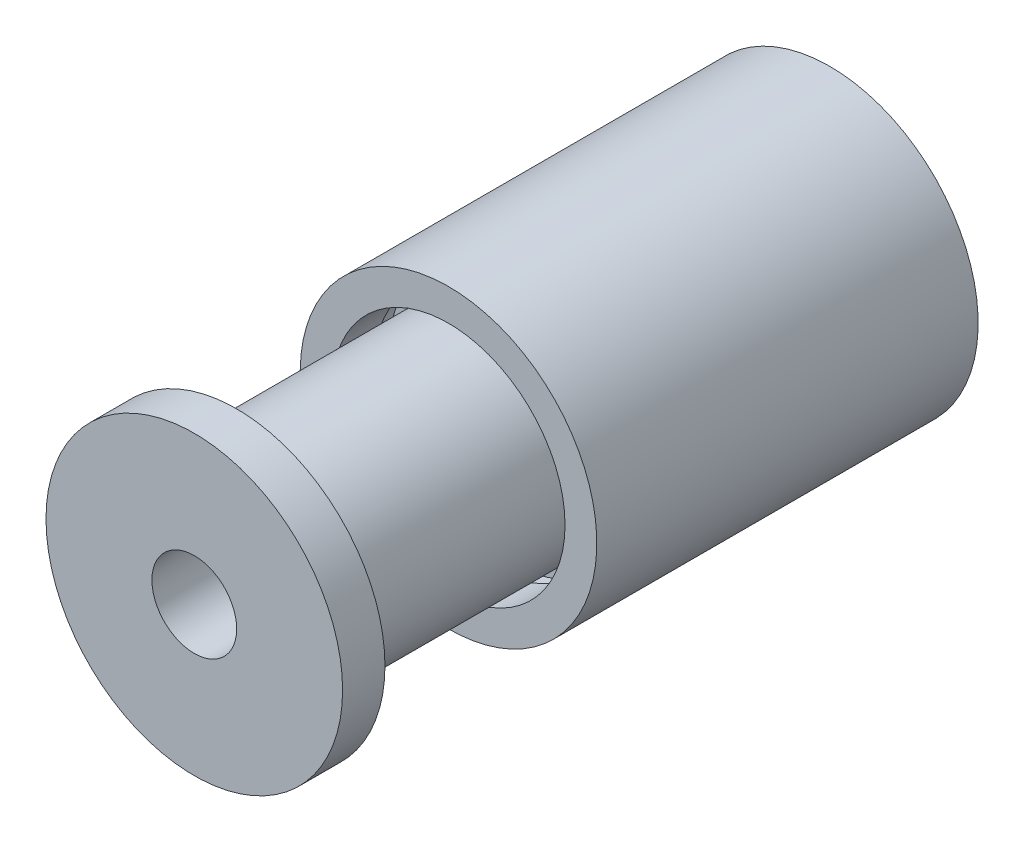
from build123d import *

# Parameters (mm, degrees)
CROQUIS1_R              = 25
CROQUIS1_R_2            = 10
SALIENTE_EXTRUIR1_DEPTH = 70
CROQUIS3_R              = 35
CROQUIS3_R_2            = 25
SALIENTE_EXTRUIR2_DEPTH = 10
CROQUIS4_R              = 30
CROQUIS4_R_2            = 27.5
SALIENTE_EXTRUIR3_DEPTH = 10
CROQUIS6_RX             = 35
CROQUIS6_RY             = 35
CROQUIS6_RX_2           = 30
CROQUIS6_RY_2           = 30
SALIENTE_EXTRUIR4_DEPTH = 90
CROQUIS7_R              = 25
CROQUIS7_R_2            = 10
SALIENTE_EXTRUIR5_DEPTH = 10
CROQUIS8_R              = 29
CROQUIS8_R_2            = 25
SALIENTE_EXTRUIR6_DEPTH = 5


with BuildPart() as part:
    # Croquis1 → Saliente-Extruir1 (new body)
    with BuildSketch(Plane.XY):
        Circle(CROQUIS1_R)
        Circle(CROQUIS1_R_2, mode=Mode.SUBTRACT)
    extrude(amount=SALIENTE_EXTRUIR1_DEPTH)

    # Croquis3 → Saliente-Extruir2 (add)
    with BuildSketch(Plane.XY.offset(70)):
        Circle(CROQUIS3_R)
        Circle(CROQUIS3_R_2, mode=Mode.SUBTRACT)
    extrude(amount=-SALIENTE_EXTRUIR2_DEPTH)

    # Croquis7 → Saliente-Extruir5 (add)
    with BuildSketch(Plane(origin=(0, 0, 0), x_dir=(-1, 0, 0), z_dir=(0, 0, -1))):
        Circle(CROQUIS7_R)
        Circle(CROQUIS7_R_2, mode=Mode.SUBTRACT)
    extrude(amount=SALIENTE_EXTRUIR5_DEPTH)

    # Croquis8 → Saliente-Extruir6 (add)
    with BuildSketch(Plane(origin=(0, 0, -10), x_dir=(-1, 0, 0), z_dir=(0, 0, -1))):
        Circle(CROQUIS8_R)
        Circle(CROQUIS8_R_2, mode=Mode.SUBTRACT)
    extrude(amount=-SALIENTE_EXTRUIR6_DEPTH)


with BuildPart() as body_2:
    # Croquis4 → Saliente-Extruir3 (new body)
    with BuildSketch(Plane(origin=(0, 0, 0), x_dir=(-1, 0, 0), z_dir=(0, 0, -1))):
        Circle(CROQUIS4_R)
        Circle(CROQUIS4_R_2, mode=Mode.SUBTRACT)
    extrude(amount=-SALIENTE_EXTRUIR3_DEPTH)

    # Croquis6 → Saliente-Extruir4 (add)
    with BuildSketch(Plane.XY.offset(10)):
        with Locations(Location((0, 0), (0, 0, -153.140460488))):
            Ellipse(CROQUIS6_RX, CROQUIS6_RY)
        with Locations(Location((0, 0), (0, 0, 145.767485293))):
            Ellipse(CROQUIS6_RX_2, CROQUIS6_RY_2, mode=Mode.SUBTRACT)
    extrude(amount=-SALIENTE_EXTRUIR4_DEPTH)


solid = Compound([part.part, body_2.part])
